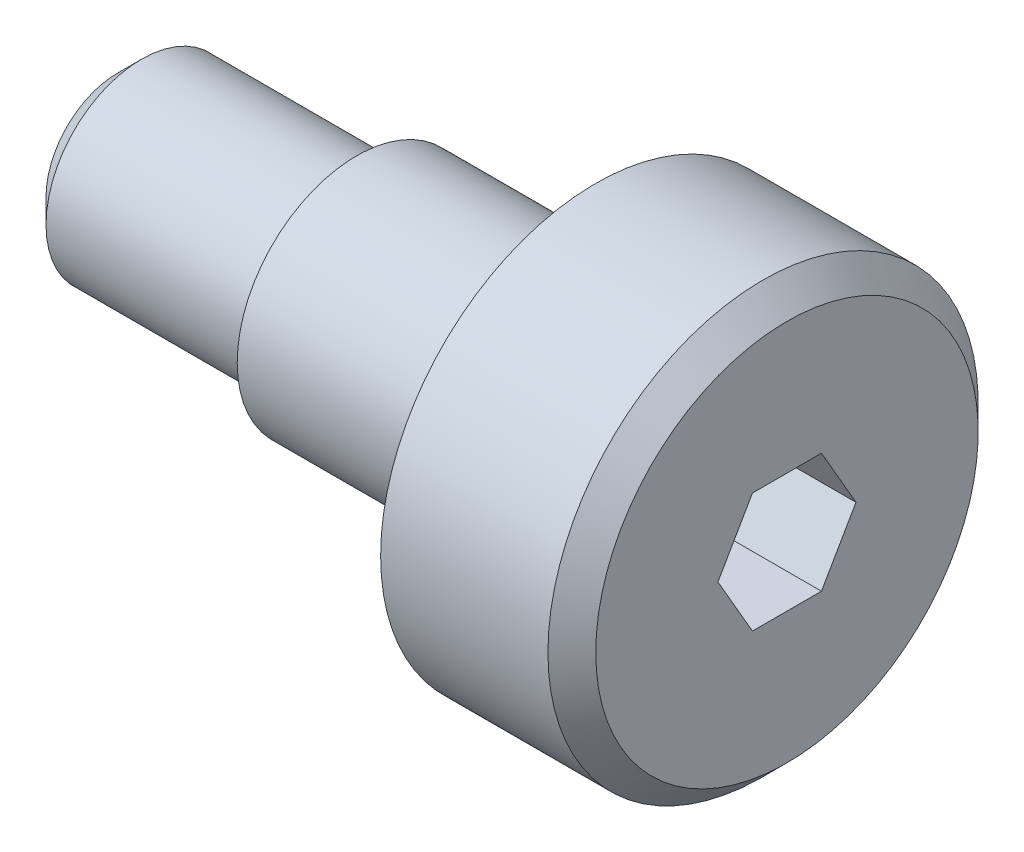
from build123d import *

# Parameters (mm, degrees)
CUT_EXTRUDE1_DEPTH = 4


with BuildPart() as part:
    # Sketch1 → Revolve1 (revolve)
    with BuildSketch(Plane.XY):
        Polygon((0, 0), (14, 0), (14, 4), (13.5, 4.5), (10, 4.5), (10, 2.5), (5, 2.5), (5, 2), (0.5, 2), (0, 1.5), align=None)
    revolve(axis=Axis((0, 0, 0), (1, 0, 0)))

    # Sketch2 → Cut-Extrude1 (cut)
    with BuildSketch(Plane(origin=(14, 0, 0), x_dir=(0, 0, -1), z_dir=(1, 0, 0))):
        Polygon((1.443375673, 0), (0.721687836, 1.25), (-0.721687836, 1.25), (-1.443375673, 0), (-0.721687836, -1.25), (0.721687836, -1.25), align=None)
    extrude(amount=-CUT_EXTRUDE1_DEPTH, mode=Mode.SUBTRACT)


solid = part.part
